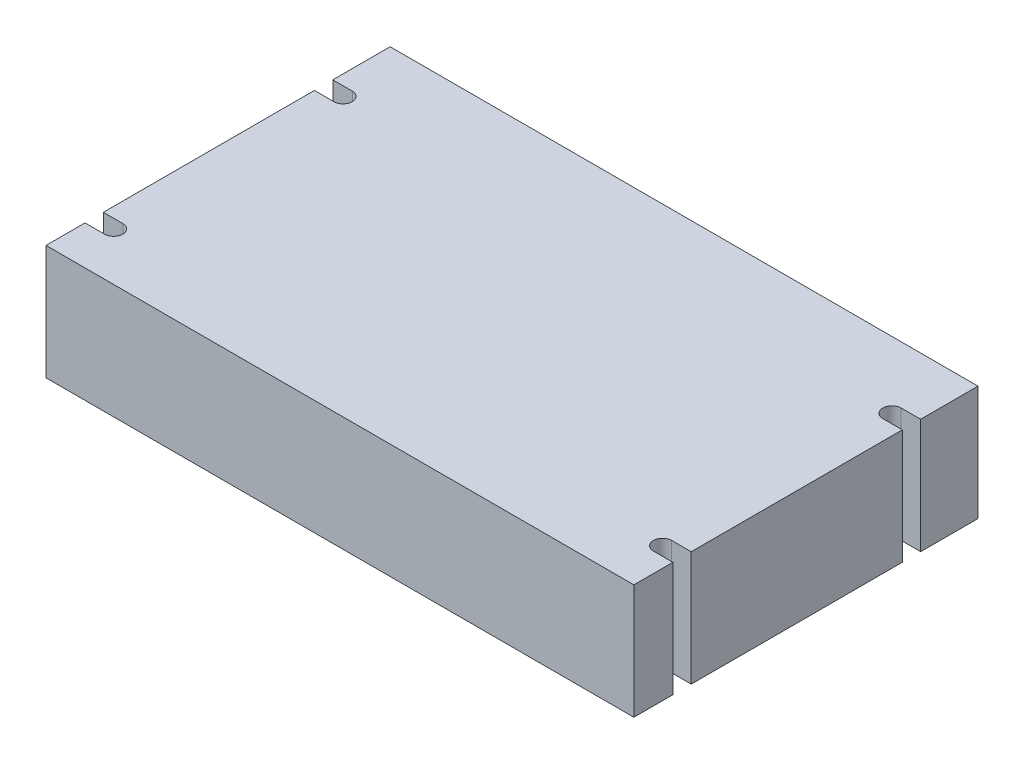
from build123d import *

# Parameters (mm, degrees)
SKETCH1_W           = 130.175
SKETCH1_H           = 76.2
BOSS_EXTRUDE1_DEPTH = 25.4
CUT_EXTRUDE1_DEPTH  = 26.4


with BuildPart() as part:
    # Sketch1 → Boss-Extrude1 (new body)
    with BuildSketch(Plane(origin=(0, 0, 0), x_dir=(1, 0, 0), z_dir=(0, 1, 0))):
        Rectangle(SKETCH1_W, SKETCH1_H)
    extrude(amount=BOSS_EXTRUDE1_DEPTH)

    # Sketch2 → Cut-Extrude1 (cut, through all)
    with BuildSketch(Plane(origin=(0, 25.4, 0), x_dir=(1, 0, 0), z_dir=(0, 1, 0))):
        with BuildLine():
            Line((-60.7695, 25.4), (-65.0875, 25.4))
            Line((-65.0875, 25.4), (-65.0875, 21.336))
            Line((-65.0875, 21.336), (-60.7695, 21.336))
            ThreePointArc((-60.7695, 21.336), (-58.7375, 23.368), (-60.7695, 25.4))
        make_face()
        with BuildLine():
            Line((-60.7695, -25.4), (-65.0875, -25.4))
            Line((-65.0875, -25.4), (-65.0875, -29.464))
            Line((-65.0875, -29.464), (-60.7695, -29.464))
            ThreePointArc((-60.7695, -29.464), (-58.7375, -27.432), (-60.7695, -25.4))
        make_face()
    cut_extrude1 = extrude(amount=-CUT_EXTRUDE1_DEPTH, mode=Mode.SUBTRACT)

    # Mirror2: Cut-Extrude1 across plane
    add(cut_extrude1.mirror(Plane(origin=(0, 0, 0), x_dir=(0, 0, 1), z_dir=(1, 0, 0))), mode=Mode.SUBTRACT)


solid = part.part
